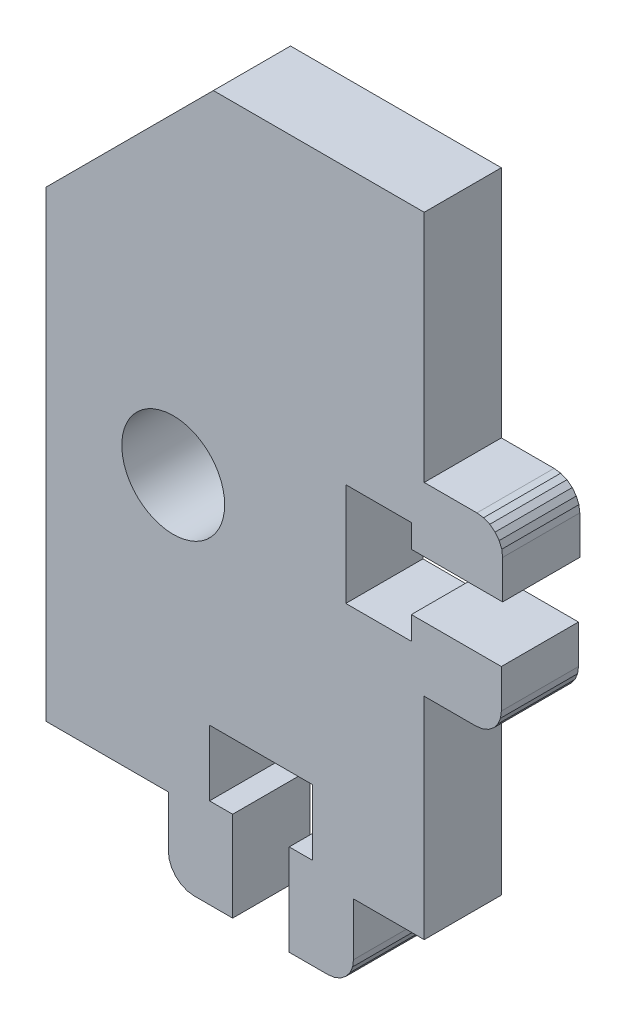
from build123d import *

# Parameters (mm, degrees)
MODEL_R                  = 4
RESSALTO_EXTRUS_O1_DEPTH = 6


with BuildPart() as part:
    # Model → Ressalto-extrusão1 (new body)
    with BuildSketch(Plane.XY):
        Polygon((52.38116631, 33.333915264), (57.481164074, 33.333915264), (57.481164074, 35.133913496), (64.481162154, 35.133913496), (64.481162154, 32.133915096), (64.413013807, 31.616277005), (64.213212962, 31.133915096), (63.895375717, 30.719701533), (63.481162154, 30.401864288), (62.998800244, 30.202063443), (62.481162154, 30.133915096), (58.481164074, 30.133915096), (58.481164074, 13.733926647), (52.981162794, 13.733926647), (52.981162794, 9.633928599), (52.913014447, 9.116290509), (52.713213602, 8.633928599), (52.395376357, 8.219715037), (51.981162794, 7.901877792), (51.498800885, 7.702076947), (50.981162794, 7.633928599), (47.981164394, 7.633928599), (47.981164394, 14.733926647), (49.781168706, 14.733926647), (49.781168706, 19.833924412), (41.781167571, 19.833924412), (41.781167571, 14.733926647), (43.581165802, 14.733926647), (43.581165802, 7.733928567), (40.581167402, 7.733928567), (40.063529312, 7.802076915), (39.581167402, 8.00187776), (39.16695384, 8.319715005), (38.849116595, 8.733928567), (38.64931575, 9.216290477), (38.581167402, 9.733928567), (38.581167402, 13.733926647), (29.081172202, 13.733926647), (29.081172202, 49.733913847), (42.081169322, 62.733910967), (58.481164074, 62.733910967), (58.481164074, 44.533910488), (62.581162122, 44.533910488), (63.098800212, 44.46576214), (63.581162122, 44.265961295), (63.995375685, 43.94812405), (64.31321293, 43.533910488), (64.513013775, 43.051548578), (64.581162122, 42.533910488), (64.581162122, 39.533912088), (57.481164074, 39.533912088), (57.481164074, 41.333916399), (52.38116631, 41.333916399), align=None)
        with Locations((38.95844444, 35.273938656)):
            Circle(MODEL_R, mode=Mode.SUBTRACT)
    extrude(amount=RESSALTO_EXTRUS_O1_DEPTH)


solid = part.part
